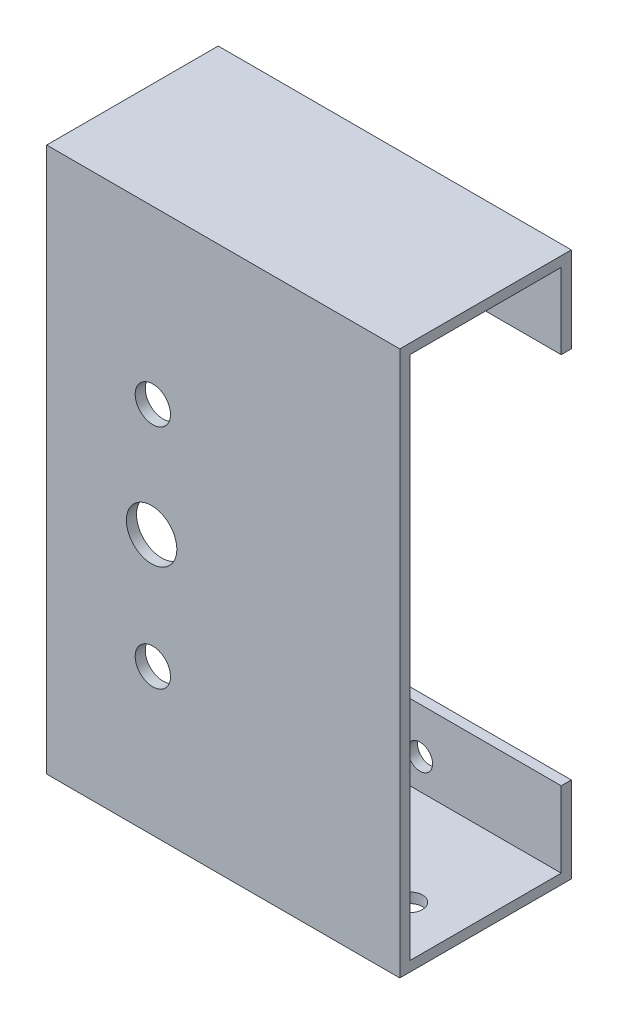
from build123d import *

# Parameters (mm, degrees)
ESBO_O1_W                = 70
ESBO_O1_H                = 108
RESSALTO_EXTRUS_O1_DEPTH = 2
ESBO_O2_W                = 70
ESBO_O2_H                = 2
RESSALTO_EXTRUS_O2_DEPTH = 30
ESBO_O3_W                = 70
ESBO_O3_H                = 17
RESSALTO_EXTRUS_O3_DEPTH = 2
ESBO_O4_R                = 2.5
CORTE_EXTRUS_O1_DEPTH    = 10
ESBO_O8_R                = 2.5
CORTE_EXTRUS_O5_DEPTH    = 10
ESBO_O9_R                = 5
CORTE_EXTRUS_O6_DEPTH    = 10
ESBO_O15_R               = 3.5
CORTE_EXTRUS_O7_DEPTH    = 10
CUT_EXTRUDE1_REACH       = 36
SKETCH1_R                = 2.5


with BuildPart() as part:
    # Esboço1 → Ressalto-extrusão1 (new body)
    with BuildSketch(Plane.XY):
        Rectangle(ESBO_O1_W, ESBO_O1_H)
    extrude(amount=RESSALTO_EXTRUS_O1_DEPTH)

    # Esboço2 → Ressalto-extrusão2 (add)
    with BuildSketch(Plane(origin=(0, 0, 0), x_dir=(-1, 0, 0), z_dir=(0, 0, -1))):
        with Locations((0, -53)):
            Rectangle(ESBO_O2_W, ESBO_O2_H)
    ressalto_extrus_o2 = extrude(amount=RESSALTO_EXTRUS_O2_DEPTH)

    # Esboço3 → Ressalto-extrusão3 (add)
    with BuildSketch(Plane(origin=(0, 0, -30), x_dir=(-1, 0, 0), z_dir=(0, 0, -1))):
        with Locations((0, -45.5)):
            Rectangle(ESBO_O3_W, ESBO_O3_H)
    ressalto_extrus_o3 = extrude(amount=RESSALTO_EXTRUS_O3_DEPTH)

    # Espelhar1: Ressalto-extrusão2, Ressalto-extrusão3 across plane
    add(ressalto_extrus_o2.mirror(Plane.ZX))
    add(ressalto_extrus_o3.mirror(Plane.ZX))

    # Esboço4 → Corte-extrusão1 (cut)
    with BuildSketch(Plane.XY.offset(-30)):
        with Locations((7, -46)):
            Circle(ESBO_O4_R)
        with Locations((18.3, 42.5)):
            Circle(ESBO_O4_R)
    extrude(amount=-CORTE_EXTRUS_O1_DEPTH, mode=Mode.SUBTRACT)

    # Esboço8 → Corte-extrusão5 (cut)
    with BuildSketch(Plane(origin=(0, -52, 0), x_dir=(1, 0, 0), z_dir=(0, 1, 0))):
        with Locations((25, 10)):
            Circle(ESBO_O8_R)
        with Locations((-25, 10)):
            Circle(ESBO_O8_R)
    extrude(amount=-CORTE_EXTRUS_O5_DEPTH, mode=Mode.SUBTRACT)

    # Esboço9 → Corte-extrusão6 (cut)
    with BuildSketch(Plane.XY.offset(2)):
        with Locations((-14.2, -2.5)):
            Circle(ESBO_O9_R)
    extrude(amount=-CORTE_EXTRUS_O6_DEPTH, mode=Mode.SUBTRACT)

    # Esboço15 → Corte-extrusão7 (cut)
    with BuildSketch(Plane.XY.offset(2)):
        with Locations((-13.954549257, 20)):
            Circle(ESBO_O15_R)
        with Locations((-13.954549257, -25)):
            Circle(ESBO_O15_R)
    extrude(amount=-CORTE_EXTRUS_O7_DEPTH, mode=Mode.SUBTRACT)

    # Sketch1 → Cut-Extrude1 (cut, up to next)
    with BuildSketch(Plane(origin=(0, 0, -32), x_dir=(-1, 0, 0), z_dir=(0, 0, -1)), mode=Mode.PRIVATE) as cut_extrude1_sk1:
        with Locations((25.5, 44.5)):
            Circle(SKETCH1_R)
    cut_extrude1_tool1 = extrude(cut_extrude1_sk1.sketch, amount=-CUT_EXTRUDE1_REACH, mode=Mode.PRIVATE) & part.part
    add(cut_extrude1_tool1.solids().sort_by_distance((-25.5, 44.5, -32))[0], mode=Mode.SUBTRACT)
    # Sketch1 → Cut-Extrude1 (cut, up to next)
    with BuildSketch(Plane(origin=(0, 0, -32), x_dir=(-1, 0, 0), z_dir=(0, 0, -1)), mode=Mode.PRIVATE) as cut_extrude1_sk2:
        with Locations((25.5, -44.5)):
            Circle(SKETCH1_R)
    cut_extrude1_tool2 = extrude(cut_extrude1_sk2.sketch, amount=-CUT_EXTRUDE1_REACH, mode=Mode.PRIVATE) & part.part
    add(cut_extrude1_tool2.solids().sort_by_distance((-25.5, -44.5, -32))[0], mode=Mode.SUBTRACT)


solid = part.part
